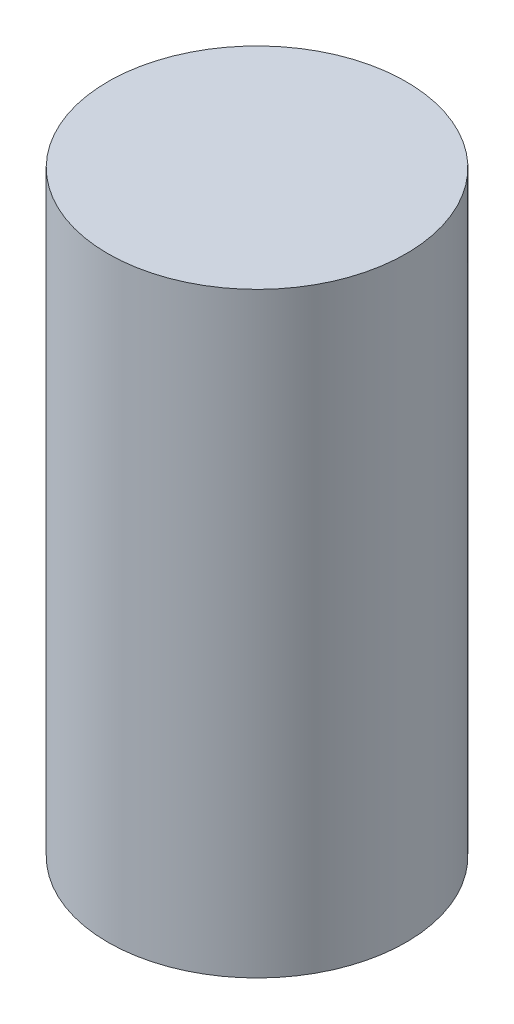
from build123d import *

# Parameters (mm, degrees)
SKETCH1_R           = 15.24
BOSS_EXTRUDE1_DEPTH = 60.96


with BuildPart() as part:
    # Sketch1 → Boss-Extrude1 (new body)
    with BuildSketch(Plane(origin=(0, 0, 0), x_dir=(1, 0, 0), z_dir=(0, 1, 0))):
        Circle(SKETCH1_R)
    extrude(amount=BOSS_EXTRUDE1_DEPTH)


solid = part.part
